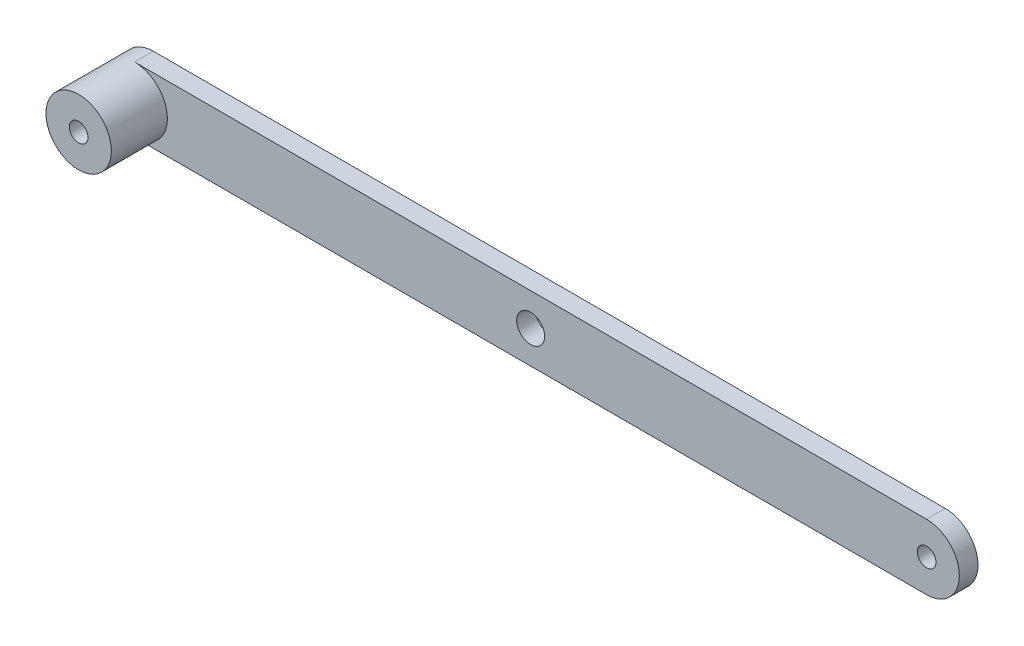
from build123d import *

# Parameters (mm, degrees)
CROQUIS1_R              = 5
CROQUIS1_R_2            = 7.5
SALIENTE_EXTRUIR1_DEPTH = 10
CROQUIS2_R              = 17.5
CROQUIS2_R_2            = 5
SALIENTE_EXTRUIR2_DEPTH = 30


with BuildPart() as part:
    # Croquis1 → Saliente-Extruir1 (new body)
    with BuildSketch(Plane.XY):
        with BuildLine():
            Line((-212, 17.5), (212, 17.5))
            ThreePointArc((212, 17.5), (229.5, 0), (212, -17.5))
            Line((212, -17.5), (-212, -17.5))
            ThreePointArc((-212, -17.5), (-229.5, 0), (-212, 17.5))
        make_face()
        with Locations((-212, 0)):
            Circle(CROQUIS1_R, mode=Mode.SUBTRACT)
        with Locations((212, 0)):
            Circle(CROQUIS1_R, mode=Mode.SUBTRACT)
        Circle(CROQUIS1_R_2, mode=Mode.SUBTRACT)
    extrude(amount=SALIENTE_EXTRUIR1_DEPTH)

    # Croquis2 → Saliente-Extruir2 (add)
    with BuildSketch(Plane.XY.offset(10)):
        with Locations((-212, 0)):
            Circle(CROQUIS2_R)
        with Locations((-212, 0)):
            Circle(CROQUIS2_R_2, mode=Mode.SUBTRACT)
    extrude(amount=SALIENTE_EXTRUIR2_DEPTH)


solid = part.part
